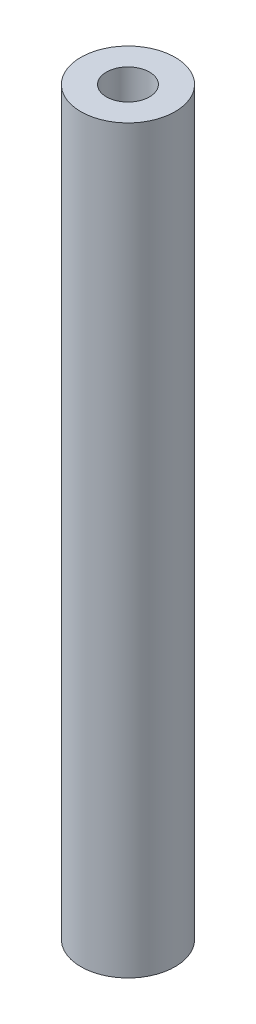
from build123d import *

# Parameters (mm, degrees)
SKETCH_1_R          = 3.5
EXTRUDE_1_DEPTH     = 55
SKETCH_2_R          = 1.6
CUT_EXTRUDE_1_DEPTH = 56


with BuildPart() as part:
    # ｽｹｯﾁ1 → ﾎﾞｽ - 押し出し1 (new body)
    with BuildSketch(Plane(origin=(0, 0, 0), x_dir=(1, 0, 0), z_dir=(0, 1, 0))):
        Circle(SKETCH_1_R)
    extrude(amount=EXTRUDE_1_DEPTH)

    # ｽｹｯﾁ2 → ｶｯﾄ - 押し出し1 (cut, through all)
    with BuildSketch(Plane(origin=(0, 55, 0), x_dir=(1, 0, 0), z_dir=(0, 1, 0))):
        Circle(SKETCH_2_R)
    extrude(amount=-CUT_EXTRUDE_1_DEPTH, mode=Mode.SUBTRACT)


solid = part.part
